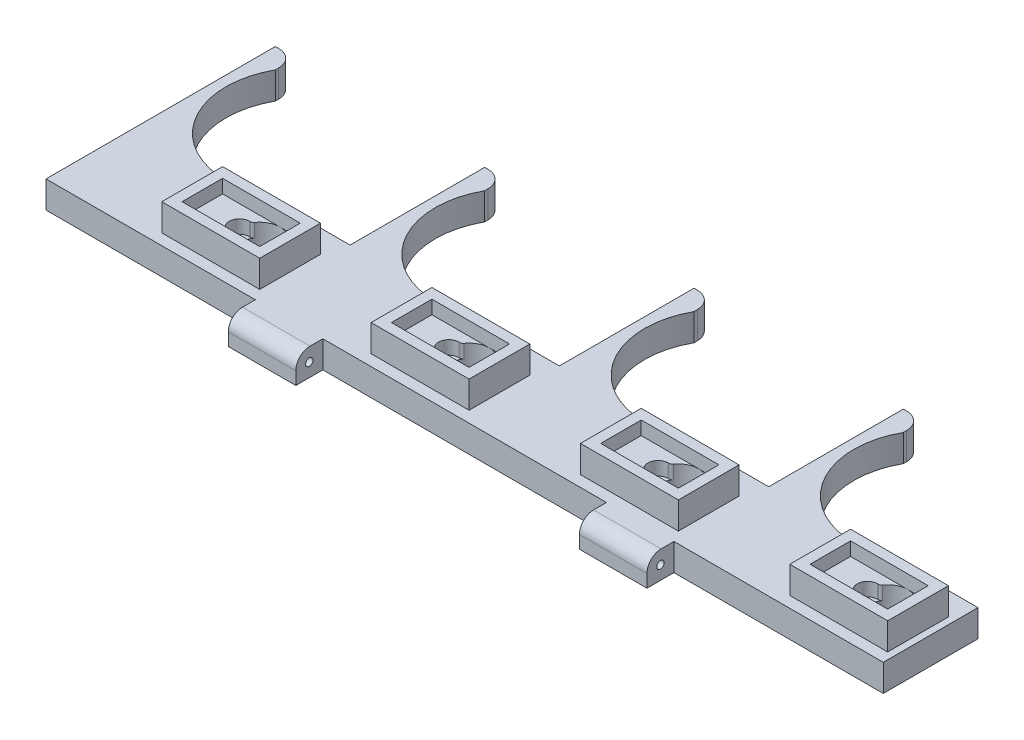
from build123d import *

# Parameters (mm, degrees)
ESQUISSE1_R                = 6
BOSS_EXTRU_1_DEPTH         = 8
ESQUISSE2_W                = 29
ESQUISSE2_H                = 18
BOSS_EXTRU_2_DEPTH         = 4
ESQUISSE3_W                = 29
ESQUISSE3_H                = 18
ESQUISSE3_W_2              = 23
ESQUISSE3_H_2              = 12
BOSS_EXTRU_3_DEPTH         = 4
ENL_V_MAT_EXTRU_1_DEPTH    = 4
R_P_TITION_LIN_AIRE1_COUNT = 4
R_P_TITION_LIN_AIRE1_PITCH = 62
ESQUISSE5_R                = 1.1
BOSS_EXTRU_4_DEPTH         = 20


with BuildPart() as part:
    # Esquisse1 → Boss.-Extru.1 (new body)
    with BuildSketch(Plane(origin=(0, 0, 0), x_dir=(1, 0, 0), z_dir=(0, 1, 0))):
        with BuildLine():
            Line((0, 0), (6, 0))
            Line((6, 0), (36, 0))
            Line((36, 0), (62, 0))
            Line((62, 0), (62, 28.055987731))
            Line((62, 28.055987731), (36, 28.055987731))
            ThreePointArc((36, 28.055987731), (9.034681758, 34.39083629), (6, 61.923533231))
            Line((6, 61.923533231), (6, 62.923533231))
            ThreePointArc((6, 62.923533231), (4.535533906, 66.459067137), (1, 67.923533231))
            Line((1, 67.923533231), (0, 67.923533231))
            Line((0, 67.923533231), (0, 0))
        make_face()
        with Locations((51, 12.304583192)):
            Circle(ESQUISSE1_R, mode=Mode.SUBTRACT)
    extrude(amount=BOSS_EXTRU_1_DEPTH)

    # Esquisse2 → Boss.-Extru.2 (add)
    with BuildSketch(Plane(origin=(0, 8, 0), x_dir=(1, 0, 0), z_dir=(0, 1, 0))):
        with Locations((45.5, 12.304583192)):
            Rectangle(ESQUISSE2_W, ESQUISSE2_H)
        with BuildLine():
            Line((45, 15.304583192), (45.255437353, 15.304583192))
            ThreePointArc((45.255437353, 15.304583192), (45.718347403, 15.418177932), (46.07608916, 15.733154621))
            ThreePointArc((46.07608916, 15.733154621), (57, 12.304583192), (46.07608916, 8.876011764))
            ThreePointArc((46.07608916, 8.876011764), (45.718347403, 9.190988453), (45.255437353, 9.304583192))
            Line((45.255437353, 9.304583192), (45, 9.304583192))
            ThreePointArc((45, 9.304583192), (42, 12.304583192), (45, 15.304583192))
        make_face(mode=Mode.SUBTRACT)
    extrude(amount=BOSS_EXTRU_2_DEPTH)

    # Esquisse3 → Boss.-Extru.3 (add)
    with BuildSketch(Plane(origin=(0, 12, 0), x_dir=(1, 0, 0), z_dir=(0, 1, 0))):
        with Locations((45.5, 12.304583192)):
            Rectangle(ESQUISSE3_W, ESQUISSE3_H)
        with Locations((45.5, 12.304583192)):
            Rectangle(ESQUISSE3_W_2, ESQUISSE3_H_2, mode=Mode.SUBTRACT)
    extrude(amount=BOSS_EXTRU_3_DEPTH)

    # Esquisse4 → Enlèv. mat.-Extru.1 (cut)
    with BuildSketch(Plane.XZ):
        Polygon((47.7, -17.055987731), (54.3, -17.055987731), (55.193703609, -16.162284122), (57.721788353, -28.055987731), (54.3, -28.055987731), (47.7, -28.055987731), (44.278211647, -28.055987731), (46.806296391, -16.162284122), align=None)
    extrude(amount=-ENL_V_MAT_EXTRU_1_DEPTH, mode=Mode.SUBTRACT)

    # Répétition linéaire1: part ×4


with BuildPart() as part_1:
    add(part.part)
    with Locations(*[(i * R_P_TITION_LIN_AIRE1_PITCH, 0, 0) for i in range(1, R_P_TITION_LIN_AIRE1_COUNT)]):
        add(part.part)

    # Esquisse5 → Boss.-Extru.4 (add)
    with BuildSketch(Plane.ZY.offset(-62)):
        with BuildLine():
            Line((0, 8), (3.8, 8))
            ThreePointArc((3.8, 8), (6.769848481, 6.769848481), (8, 3.8))
            Line((8, 3.8), (8, 0))
            Line((8, 0), (0, 0))
            Line((0, 0), (0, 8))
        make_face()
        with Locations((4, 4)):
            Circle(ESQUISSE5_R, mode=Mode.SUBTRACT)
    boss_extru_4 = extrude(amount=-BOSS_EXTRU_4_DEPTH)

    # Symétrie1: Boss.-Extru.4 across plane
    add(boss_extru_4.mirror(Plane(origin=(124, 8, 0), x_dir=(0, 0, 1), z_dir=(1, 0, 0))))


solid = part_1.part
